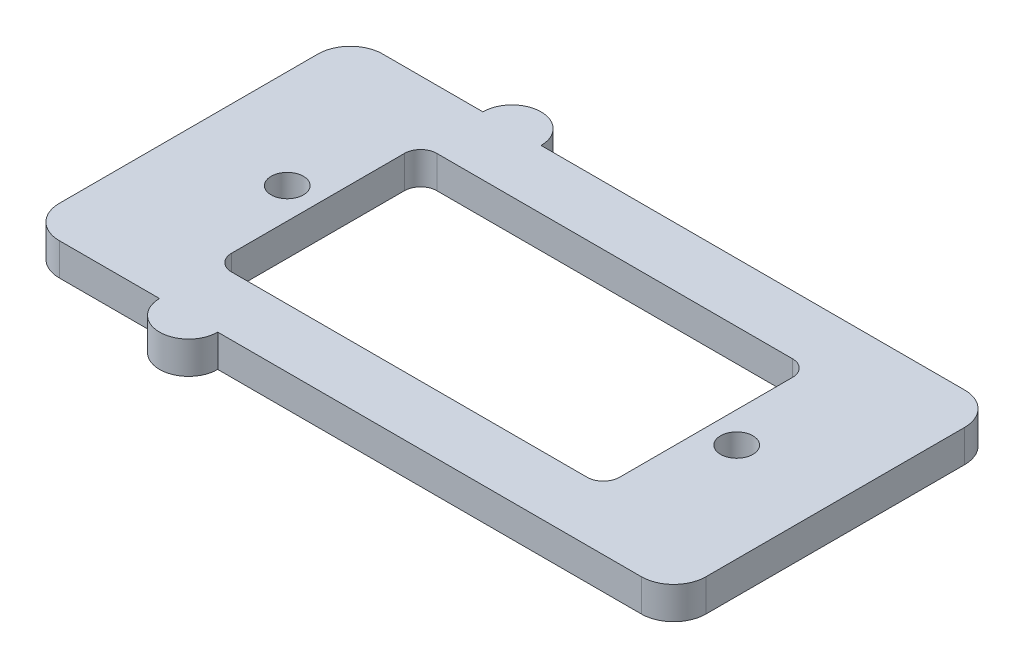
from build123d import *

# Parameters (mm, degrees)
ESQUISSE1_R        = 1.8
ESQUISSE1_R_2      = 1
BOSS_EXTRU_1_DEPTH = 2


with BuildPart() as part:
    # Esquisse1 → Boss.-Extru.1 (new body)
    with BuildSketch(Plane(origin=(0, 0, 0), x_dir=(1, 0, 0), z_dir=(0, 1, 0))):
        with Locations((-10, 10)):
            Circle(ESQUISSE1_R)
        with Locations((-10, -10)):
            Circle(ESQUISSE1_R)
        with BuildLine():
            Line((-18, -10), (18, -10))
            ThreePointArc((18, -10), (19.414213562, -9.414213562), (20, -8))
            Line((20, -8), (20, 8))
            ThreePointArc((20, 8), (19.414213562, 9.414213562), (18, 10))
            Line((18, 10), (-18, 10))
            ThreePointArc((-18, 10), (-19.414213562, 9.414213562), (-20, 8))
            Line((-20, 8), (-20, -8))
            ThreePointArc((-20, -8), (-19.414213562, -9.414213562), (-18, -10))
        make_face()
        with Locations(Location((13.9, 0, 0), (0, 0, 270))):  # turned: the seam where the file's is
            Circle(ESQUISSE1_R_2, mode=Mode.SUBTRACT)
        with Locations(Location((-13.9, 0, 0), (0, 0, 270))):  # turned: the seam where the file's is
            Circle(ESQUISSE1_R_2, mode=Mode.SUBTRACT)
        with BuildLine():
            Line((-11, -6.35), (11, -6.35))
            ThreePointArc((11, -6.35), (11.707106781, -6.057106781), (12, -5.35))
            Line((12, -5.35), (12, 5.35))
            ThreePointArc((12, 5.35), (11.707106781, 6.057106781), (11, 6.35))
            Line((11, 6.35), (-11, 6.35))
            ThreePointArc((-11, 6.35), (-11.707106781, 6.057106781), (-12, 5.35))
            Line((-12, 5.35), (-12, -5.35))
            ThreePointArc((-12, -5.35), (-11.707106781, -6.057106781), (-11, -6.35))
        make_face(mode=Mode.SUBTRACT)
    extrude(amount=BOSS_EXTRU_1_DEPTH)


solid = part.part
